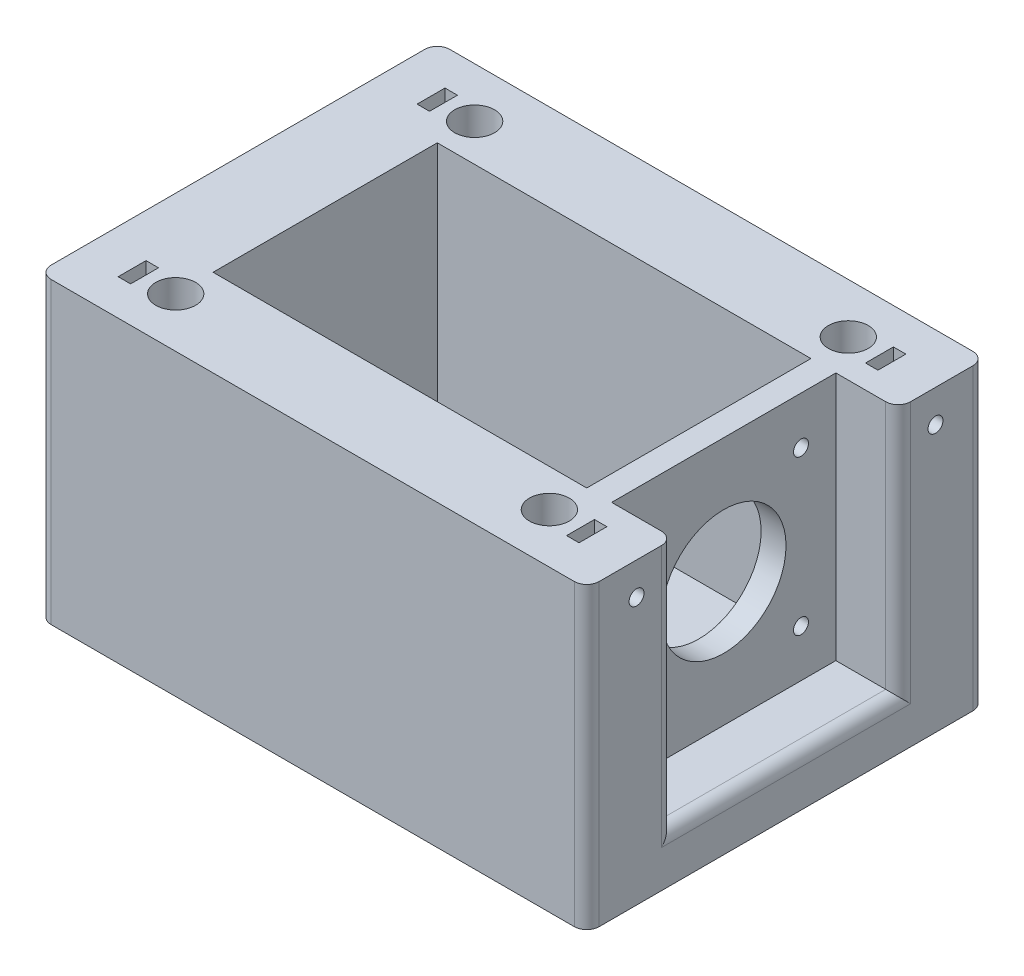
from build123d import *

# Parameters (mm, degrees)
SKETCH1_W           = 110
SKETCH1_H           = 80
BOSS_EXTRUDE1_DEPTH = 60
SKETCH2_W           = 75
SKETCH2_H           = 45
SKETCH2_W_2         = 12.5
CUT_EXTRUDE2_DEPTH  = 50
SKETCH4_W           = 1.25
SKETCH4_H           = 2.8
CUT_EXTRUDE3_DEPTH  = 10
SKETCH5_R           = 1.5
CUT_EXTRUDE4_DEPTH  = 117
SKETCH6_R           = 12.5
CUT_EXTRUDE5_DEPTH  = 5
FILLET1_R           = 2.5


with BuildPart() as part:
    # Sketch1 → Boss-Extrude1 (new body)
    with BuildSketch(Plane(origin=(0, 0, 0), x_dir=(1, 0, 0), z_dir=(0, 1, 0))):
        Rectangle(SKETCH1_W, SKETCH1_H)
    extrude(amount=BOSS_EXTRUDE1_DEPTH)

    # Sketch2 → Cut-Extrude2 (cut)
    with BuildSketch(Plane(origin=(0, 60, 0), x_dir=(1, 0, 0), z_dir=(0, 1, 0))):
        Rectangle(SKETCH2_W, SKETCH2_H)
        with BuildLine():
            ThreePointArc((-33.5, 30), (-40.328427125, 32.828427125), (-37.5, 26))
            Line((-37.5, 26), (-37.5, 30))
            Line((-37.5, 30), (-33.5, 30))
        make_face()
        with BuildLine():
            Line((-37.5, 30), (-37.5, 26))
            ThreePointArc((-37.5, 26), (-34.671572875, 27.171572875), (-33.5, 30))
            Line((-33.5, 30), (-37.5, 30))
        make_face()
        with BuildLine():
            ThreePointArc((33.5, 30), (34.671572875, 27.171572875), (37.5, 26))
            Line((37.5, 26), (37.5, 30))
            Line((37.5, 30), (33.5, 30))
        make_face()
        with BuildLine():
            Line((37.5, 30), (37.5, 26))
            ThreePointArc((37.5, 26), (40.328427125, 27.171572875), (41.5, 30))
            ThreePointArc((41.5, 30), (37.5, 34), (33.5, 30))
            Line((33.5, 30), (37.5, 30))
        make_face()
        with BuildLine():
            ThreePointArc((-33.5, -30), (-34.671572875, -27.171572875), (-37.5, -26))
            Line((-37.5, -26), (-37.5, -30))
            Line((-37.5, -30), (-33.5, -30))
        make_face()
        with BuildLine():
            Line((-37.5, -30), (-37.5, -26))
            ThreePointArc((-37.5, -26), (-40.328427125, -32.828427125), (-33.5, -30))
            Line((-33.5, -30), (-37.5, -30))
        make_face()
        with BuildLine():
            ThreePointArc((41.5, -30), (40.328427125, -27.171572875), (37.5, -26))
            Line((37.5, -26), (37.5, -30))
            Line((37.5, -30), (33.5, -30))
            ThreePointArc((33.5, -30), (37.5, -34), (41.5, -30))
        make_face()
        with BuildLine():
            Line((37.5, -30), (37.5, -26))
            ThreePointArc((37.5, -26), (34.671572875, -27.171572875), (33.5, -30))
            Line((33.5, -30), (37.5, -30))
        make_face()
        with Locations((48.75, 0)):
            Rectangle(SKETCH2_W_2, SKETCH2_H)
    extrude(amount=-CUT_EXTRUDE2_DEPTH, mode=Mode.SUBTRACT)

    # Sketch4 → Cut-Extrude3 (cut)
    with BuildSketch(Plane(origin=(0, 60, 0), x_dir=(1, 0, 0), z_dir=(0, 1, 0))):
        Polygon((-45, 27.2), (-45, 30), (-43.75, 30), (-43.75, 32.8), (-46.25, 32.8), (-46.25, 27.2), align=None)
        with Locations((-44.375, 28.6)):
            Rectangle(SKETCH4_W, SKETCH4_H)
        Polygon((-45, -30), (-45, -27.2), (-46.25, -27.2), (-46.25, -32.8), (-43.75, -32.8), (-43.75, -30), align=None)
        with Locations((-44.375, -28.6)):
            Rectangle(SKETCH4_W, SKETCH4_H)
        with Locations((44.375, -28.6)):
            Rectangle(SKETCH4_W, SKETCH4_H)
        Polygon((46.25, -27.2), (45, -27.2), (45, -30), (43.75, -30), (43.75, -32.8), (46.25, -32.8), align=None)
        Polygon((43.75, 32.8), (43.75, 30), (45, 30), (45, 27.2), (46.25, 27.2), (46.25, 32.8), align=None)
        with Locations((44.375, 28.6)):
            Rectangle(SKETCH4_W, SKETCH4_H)
    extrude(amount=-CUT_EXTRUDE3_DEPTH, mode=Mode.SUBTRACT)

    # Sketch5 → Cut-Extrude4 (cut)
    with BuildSketch(Plane(origin=(55, 0, 0), x_dir=(0, 0, -1), z_dir=(1, 0, 0))):
        with Locations((-30, 53.5)):
            Circle(SKETCH5_R)
        with Locations((30, 53.5)):
            Circle(SKETCH5_R)
    extrude(amount=-CUT_EXTRUDE4_DEPTH, mode=Mode.SUBTRACT)

    # Sketch6 → Cut-Extrude5 (cut)
    with BuildSketch(Plane(origin=(42.5, 0, 0), x_dir=(0, 0, -1), z_dir=(1, 0, 0))):
        with Locations((0, 35)):
            Circle(SKETCH6_R)
        with BuildLine():
            Line((-15.5, 49), (-15.5, 50.5))
            Line((-15.5, 50.5), (-14, 50.5))
            ThreePointArc((-14, 50.5), (-16.560660172, 51.560660172), (-15.5, 49))
        make_face()
        with BuildLine():
            Line((-14, 50.5), (-15.5, 50.5))
            Line((-15.5, 50.5), (-15.5, 49))
            ThreePointArc((-15.5, 49), (-14.439339828, 49.439339828), (-14, 50.5))
        make_face()
        with BuildLine():
            ThreePointArc((17, 50.5), (15.5, 52), (14, 50.5))
            Line((14, 50.5), (15.5, 50.5))
            Line((15.5, 50.5), (15.5, 49))
            ThreePointArc((15.5, 49), (16.560660172, 49.439339828), (17, 50.5))
        make_face()
        with BuildLine():
            Line((15.5, 50.5), (14, 50.5))
            ThreePointArc((14, 50.5), (14.439339828, 49.439339828), (15.5, 49))
            Line((15.5, 49), (15.5, 50.5))
        make_face()
        with BuildLine():
            ThreePointArc((17, 19.5), (16.560660172, 20.560660172), (15.5, 21))
            Line((15.5, 21), (15.5, 19.5))
            Line((15.5, 19.5), (14, 19.5))
            ThreePointArc((14, 19.5), (15.5, 18), (17, 19.5))
        make_face()
        with BuildLine():
            Line((15.5, 19.5), (15.5, 21))
            ThreePointArc((15.5, 21), (14.439339828, 20.560660172), (14, 19.5))
            Line((14, 19.5), (15.5, 19.5))
        make_face()
        with BuildLine():
            ThreePointArc((-14, 19.5), (-14.439339828, 20.560660172), (-15.5, 21))
            Line((-15.5, 21), (-15.5, 19.5))
            Line((-15.5, 19.5), (-14, 19.5))
        make_face()
        with BuildLine():
            Line((-15.5, 19.5), (-15.5, 21))
            ThreePointArc((-15.5, 21), (-16.560660172, 18.439339828), (-14, 19.5))
            Line((-14, 19.5), (-15.5, 19.5))
        make_face()
    extrude(amount=-CUT_EXTRUDE5_DEPTH, mode=Mode.SUBTRACT)

    # Fillet1
    fillet1_edges = [part.edges().sort_by_distance(p)[0] for p in [
        (55, 10, 0),
        (55, 35, -22.5),
        (55, 35, 22.5),
        (55, 30, 40),
        (-55, 30, 40),
        (-55, 30, -40),
        (55, 30, -40),
    ]]
    fillet(fillet1_edges, radius=FILLET1_R)


solid = part.part
